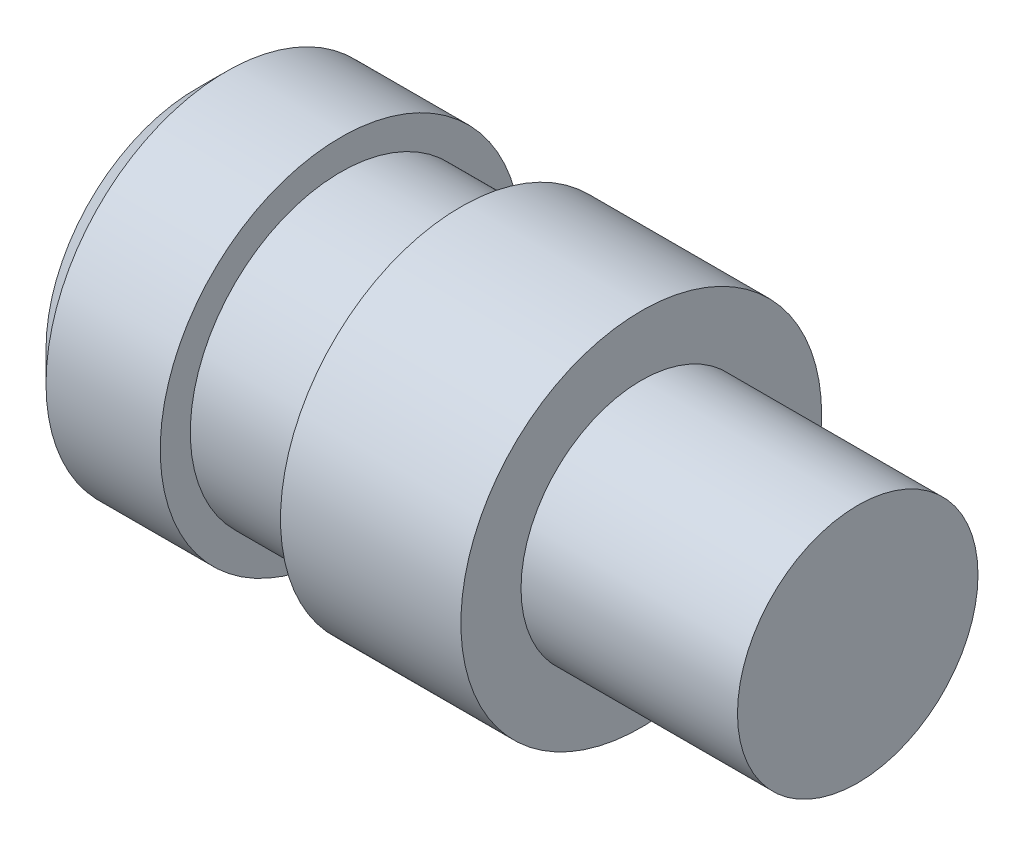
from build123d import *

# Parameters (mm, degrees)
CHANFREIN1_SIZE = 0.5


with BuildPart() as part:
    # Esquisse1 → Révolution1 (revolve)
    with BuildSketch(Plane.XY, mode=Mode.PRIVATE) as r_volution1_sk:
        Polygon((0, 0), (0, 3), (2.4, 3), (2.4, 2.5), (4.4, 2.5), (4.4, 3), (7.4, 3), (7.4, 2), (11, 2), (11, 0), align=None)
    revolve(r_volution1_sk.sketch.rotate(Axis((11, 0, 0), (-1, 0, 0)), 90), axis=Axis((11, 0, 0), (-1, 0, 0)))  # turned: the seam where the file's is

    # Chanfrein1
    chanfrein1_edges = [part.edges().sort_by_distance(p)[0] for p in [
        (0, 0, 3),
    ]]
    chamfer(chanfrein1_edges, length=CHANFREIN1_SIZE)


solid = part.part
